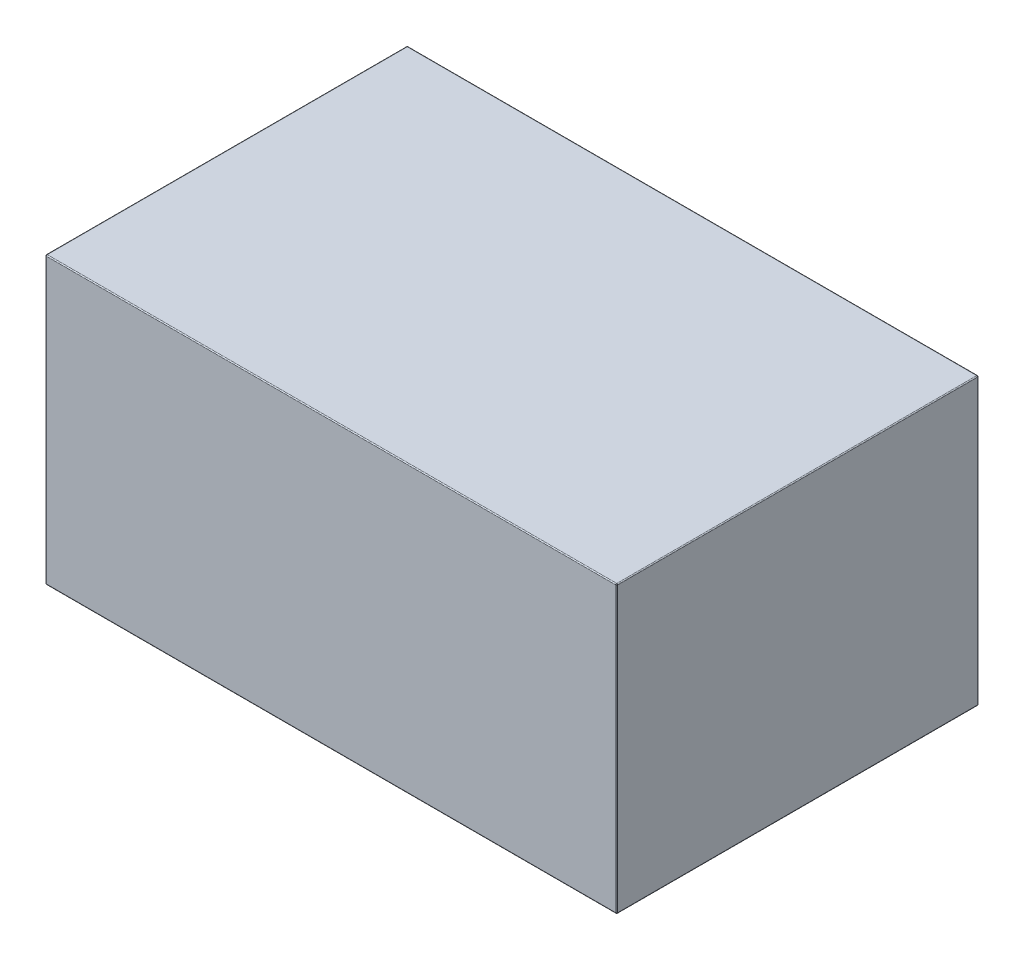
from build123d import *

# Parameters (mm, degrees)
SKETCH1_W           = 152.4
SKETCH1_H           = 96.52
BOSS_EXTRUDE1_DEPTH = 38.1
FILLET1_R           = 0.254


with BuildPart() as part:
    # Sketch1 → Boss-Extrude1 (new body, symmetric)
    with BuildSketch(Plane(origin=(0, 0, 0), x_dir=(1, 0, 0), z_dir=(0, 1, 0))):
        Rectangle(SKETCH1_W, SKETCH1_H)
    extrude(amount=BOSS_EXTRUDE1_DEPTH, both=True)

    # Fillet1
    fillet1_edges = [part.edges().sort_by_distance(p)[0] for p in [
        (-76.2, 38.1, 0),
        (0, 38.1, 48.26),
        (76.2, 38.1, 0),
        (0, -38.1, 48.26),
        (-76.2, -38.1, 0),
        (0, -38.1, -48.26),
        (76.2, -38.1, 0),
        (76.2, 0, 48.26),
        (-76.2, 0, 48.26),
        (-76.2, 0, -48.26),
        (76.2, 0, -48.26),
        (0, 38.1, -48.26),
    ]]
    fillet(fillet1_edges, radius=FILLET1_R)


solid = part.part
